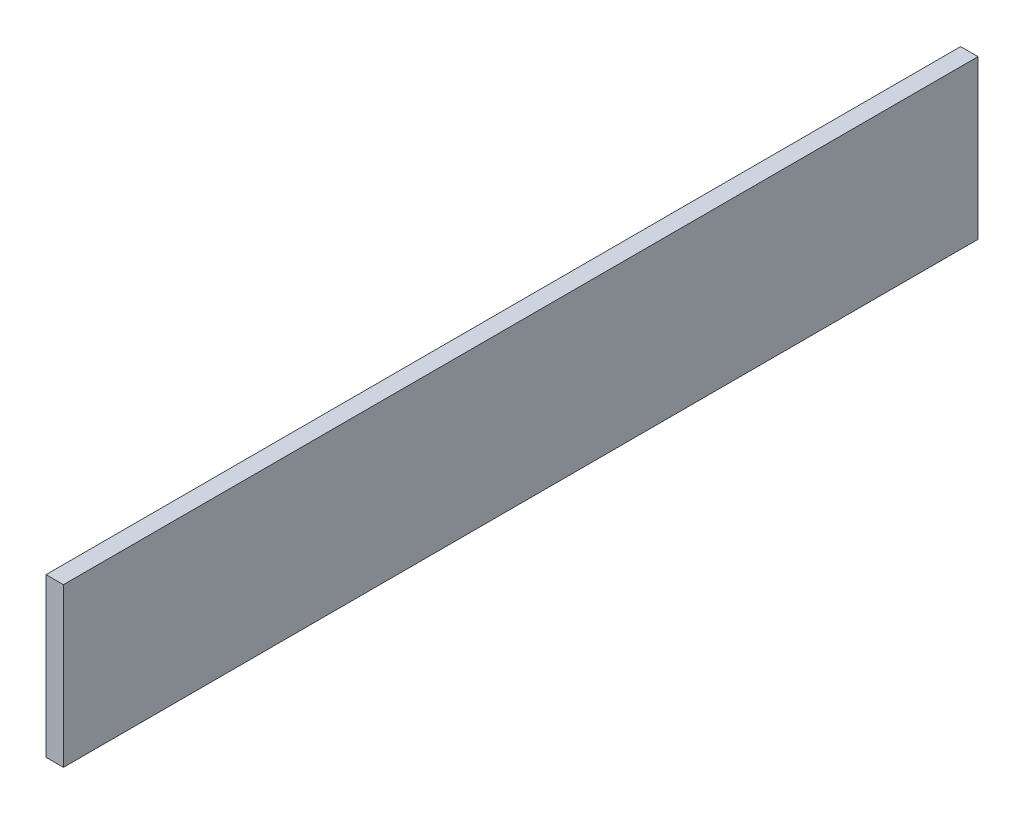
from build123d import *

# Parameters (mm, degrees)
SKETCH1_W           = 1156
SKETCH1_H           = 200
BOSS_EXTRUDE1_DEPTH = 22


with BuildPart() as part:
    # Sketch1 → Boss-Extrude1 (new body)
    with BuildSketch(Plane(origin=(0, 0, 0), x_dir=(0, 0, -1), z_dir=(1, 0, 0))):
        Rectangle(SKETCH1_W, SKETCH1_H)
    extrude(amount=BOSS_EXTRUDE1_DEPTH)


solid = part.part
